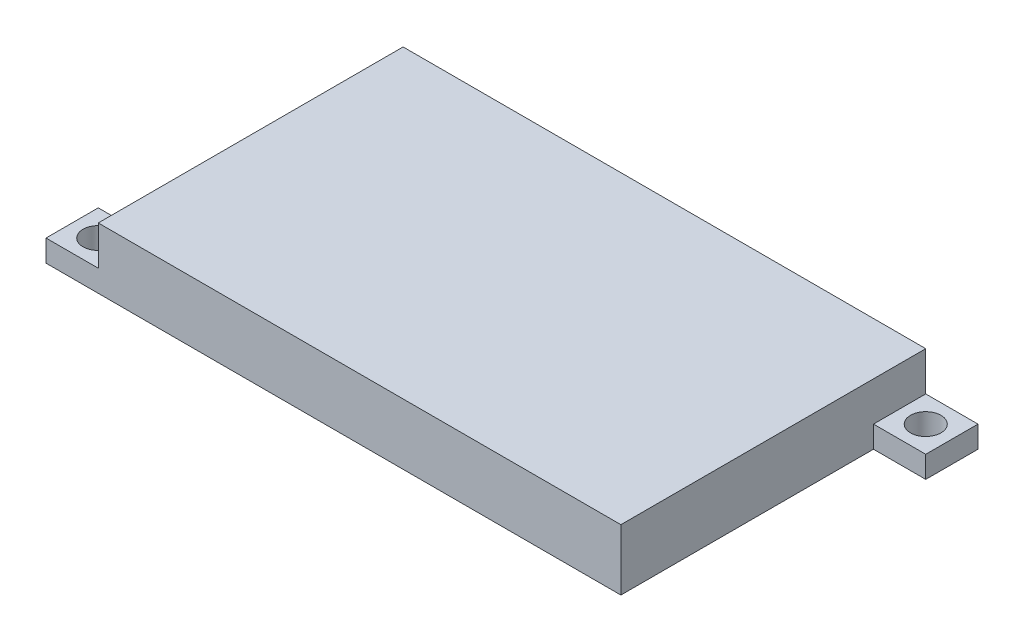
from build123d import *

# Parameters (mm, degrees)
SKETCH1_W           = 60
SKETCH1_H           = 35
BOSS_EXTRUDE1_DEPTH = 7
SKETCH3_W           = 6
SKETCH3_H           = 6
SKETCH3_R           = 1.75
BOSS_EXTRUDE2_DEPTH = 2.5
SKETCH4_W           = 55
SKETCH4_H           = 31
CUT_EXTRUDE1_DEPTH  = 5


with BuildPart() as part:
    # Sketch1 → Boss-Extrude1 (new body)
    with BuildSketch(Plane(origin=(0, 0, 0), x_dir=(1, 0, 0), z_dir=(0, 1, 0))):
        Rectangle(SKETCH1_W, SKETCH1_H)
    extrude(amount=BOSS_EXTRUDE1_DEPTH)

    # Sketch3 → Boss-Extrude2 (add)
    with BuildSketch(Plane(origin=(0, 0, 0), x_dir=(1, 0, 0), z_dir=(0, 1, 0))):
        with Locations((-33, -14.5)):
            Rectangle(SKETCH3_W, SKETCH3_H)
        with Locations(Location((-33, -14.5, 0), (0, 0, 90))):  # turned: the seam where the file's is
            Circle(SKETCH3_R, mode=Mode.SUBTRACT)
        with Locations((33, 14.5)):
            Rectangle(SKETCH3_W, SKETCH3_H)
        with Locations(Location((33, 14.5, 0), (0, 0, 90))):  # turned: the seam where the file's is
            Circle(SKETCH3_R, mode=Mode.SUBTRACT)
    extrude(amount=BOSS_EXTRUDE2_DEPTH)

    # Sketch4 → Cut-Extrude1 (cut)
    with BuildSketch(Plane(origin=(0, 0, 0), x_dir=(-1, 0, 0), z_dir=(0, -1, 0))):
        Rectangle(SKETCH4_W, SKETCH4_H)
    extrude(amount=-CUT_EXTRUDE1_DEPTH, mode=Mode.SUBTRACT)


solid = part.part
